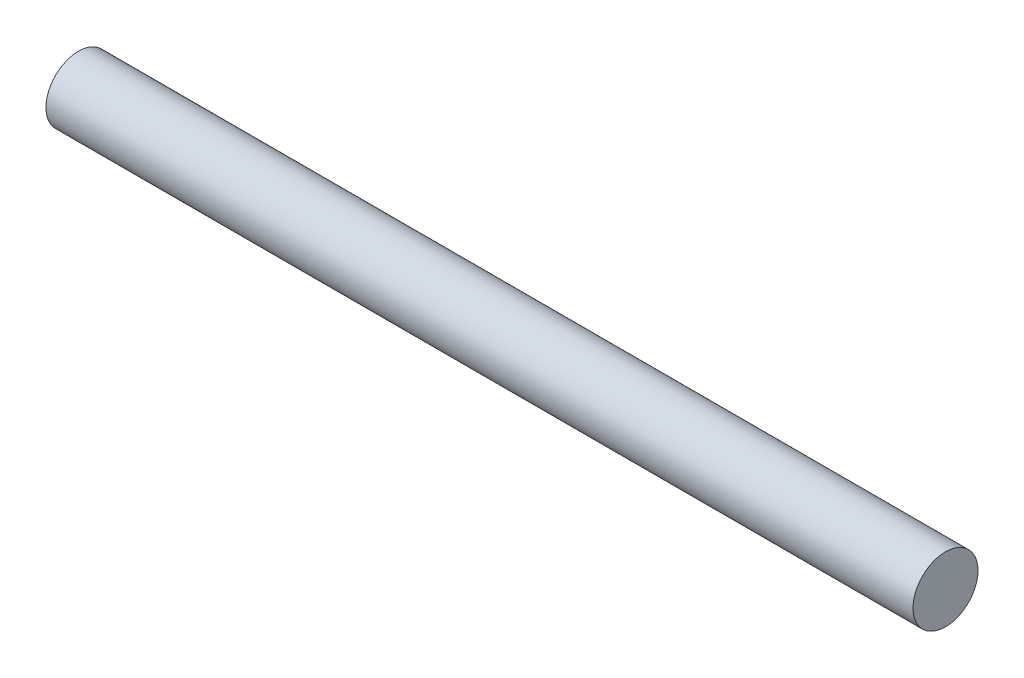
from build123d import *

# Parameters (mm, degrees)
SKETCH1_R           = 9.525
BOSS_EXTRUDE1_DEPTH = 127


with BuildPart() as part:
    # Sketch1 → Boss-Extrude1 (new body, symmetric)
    with BuildSketch(Plane(origin=(0, 0, 0), x_dir=(0, 0, -1), z_dir=(1, 0, 0))):
        Circle(SKETCH1_R)
    extrude(amount=BOSS_EXTRUDE1_DEPTH, both=True)


solid = part.part
